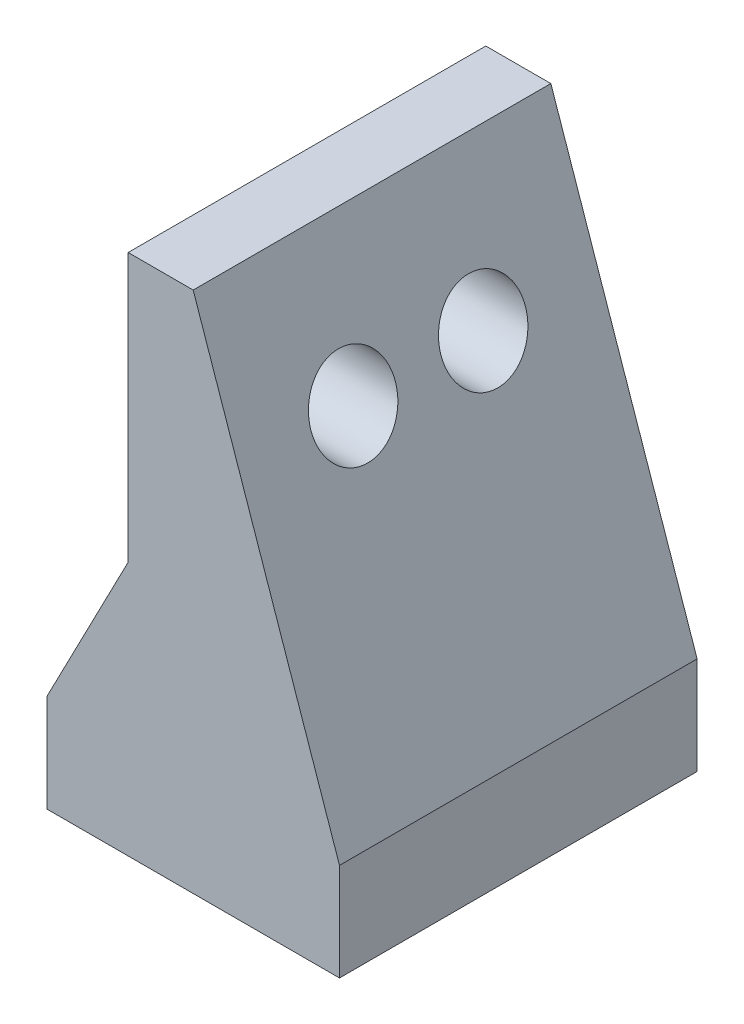
from build123d import *

# Parameters (mm, degrees)
BOSS_EXTRUDE1_DEPTH = 22
SKETCH2_R           = 2.6
CUT_EXTRUDE1_DEPTH  = 14
SKETCH3_R           = 2.6
CUT_EXTRUDE2_DEPTH  = 6
CHAMFER1_SIZE       = 1


with BuildPart() as part:
    # Sketch1 → Boss-Extrude1 (new body)
    with BuildSketch(Plane.XY):
        Polygon((0, 0), (0, 6), (5, 15.65), (5, 32.15), (9, 32.15), (18, 6), (18, 0), align=None)
    extrude(amount=BOSS_EXTRUDE1_DEPTH)

    # Sketch2 → Cut-Extrude1 (cut, through all)
    with BuildSketch(Plane.ZY.offset(-5)):
        with Locations((7, 23.9)):
            Circle(SKETCH2_R)
        with Locations((15, 23.9)):
            Circle(SKETCH2_R)
    extrude(amount=-CUT_EXTRUDE1_DEPTH, mode=Mode.SUBTRACT)

    # Sketch3 → Cut-Extrude2 (cut)
    with BuildSketch(Plane.XZ):
        with Locations((5, 17)):
            Circle(SKETCH3_R)
        with Locations((13, 11)):
            Circle(SKETCH3_R)
        with Locations((5, 5)):
            Circle(SKETCH3_R)
    extrude(amount=-CUT_EXTRUDE2_DEPTH, mode=Mode.SUBTRACT)

    # Chamfer1
    chamfer1_edges = [part.edges().sort_by_distance(p)[0] for p in [
        (5, 23.9, 4.4),
        (5, 23.9, 12.4),
        (2.4, 0, 17),
        (10.4, 0, 11),
        (2.4, 0, 5),
    ]]
    chamfer(chamfer1_edges, length=CHAMFER1_SIZE)


solid = part.part
